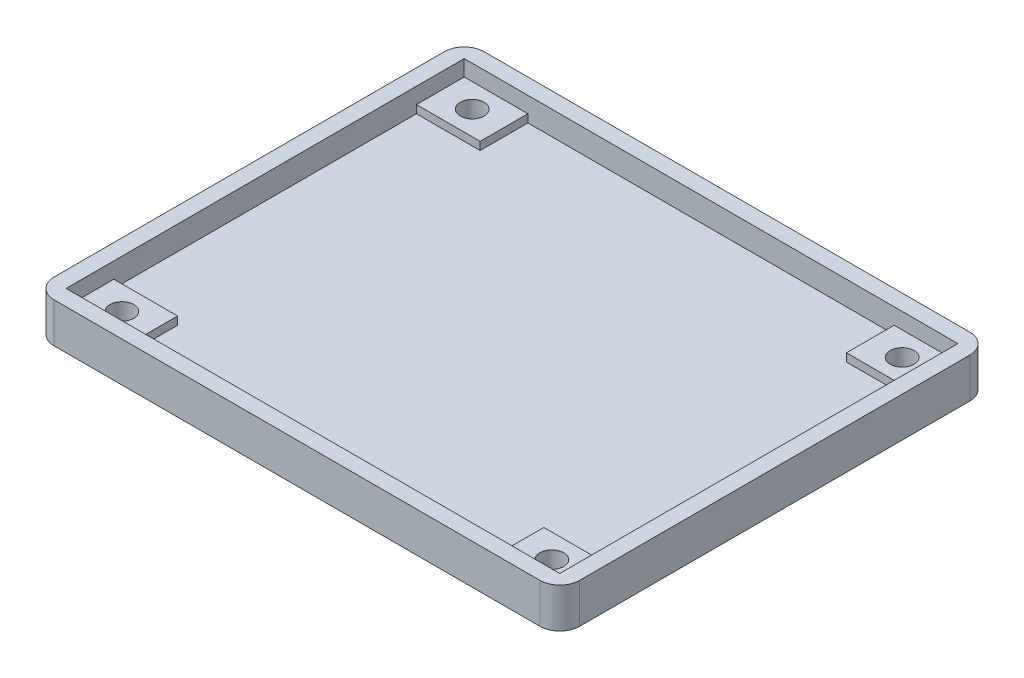
from build123d import *

# Parameters (mm, degrees)
SKETCH1_W           = 66
SKETCH1_H           = 54
BOSS_EXTRUDE1_DEPTH = 5
SKETCH2_W           = 62
SKETCH2_H           = 50
CUT_EXTRUDE1_DEPTH  = 3
SKETCH3_W           = 8
SKETCH3_H           = 6
SKETCH3_R           = 1.5
BOSS_EXTRUDE2_DEPTH = 3
SKETCH4_R           = 1.5
CUT_EXTRUDE2_DEPTH  = 3
FILLET1_R           = 2.5


with BuildPart() as part:
    # Sketch1 → Boss-Extrude1 (new body)
    with BuildSketch(Plane(origin=(0, 0, 0), x_dir=(1, 0, 0), z_dir=(0, 1, 0))):
        Rectangle(SKETCH1_W, SKETCH1_H)
    extrude(amount=BOSS_EXTRUDE1_DEPTH)

    # Sketch2 → Cut-Extrude1 (cut)
    with BuildSketch(Plane(origin=(0, 5, 0), x_dir=(1, 0, 0), z_dir=(0, 1, 0))):
        Rectangle(SKETCH2_W, SKETCH2_H)
    extrude(amount=-CUT_EXTRUDE1_DEPTH, mode=Mode.SUBTRACT)

    # Sketch3 → Boss-Extrude2 (add)
    with BuildSketch(Plane(origin=(0, 0, 0), x_dir=(1, 0, 0), z_dir=(0, 1, 0))):
        with Locations((-27, -22)):
            Rectangle(SKETCH3_W, SKETCH3_H)
        with Locations((-27, -22)):
            Circle(SKETCH3_R, mode=Mode.SUBTRACT)
        with Locations((-27, 22)):
            Rectangle(SKETCH3_W, SKETCH3_H)
        with Locations((-27, 22)):
            Circle(SKETCH3_R, mode=Mode.SUBTRACT)
        with Locations((27, -22)):
            Rectangle(SKETCH3_W, SKETCH3_H)
        with Locations((27, -22)):
            Circle(SKETCH3_R, mode=Mode.SUBTRACT)
        with Locations((27, 22)):
            Rectangle(SKETCH3_W, SKETCH3_H)
        with Locations((27, 22)):
            Circle(SKETCH3_R, mode=Mode.SUBTRACT)
    extrude(amount=BOSS_EXTRUDE2_DEPTH)

    # Sketch4 → Cut-Extrude2 (cut)
    with BuildSketch(Plane(origin=(0, 2, 0), x_dir=(1, 0, 0), z_dir=(0, 1, 0))):
        with Locations((-27, 22)):
            Circle(SKETCH4_R)
        with Locations((-27, -22)):
            Circle(SKETCH4_R)
        with Locations((27, -22)):
            Circle(SKETCH4_R)
        with Locations((27, 22)):
            Circle(SKETCH4_R)
    extrude(amount=-CUT_EXTRUDE2_DEPTH, mode=Mode.SUBTRACT)

    # Fillet1
    fillet1_edges = [part.edges().sort_by_distance(p)[0] for p in [
        (33, 2.5, 27),
        (-33, 2.5, 27),
        (-33, 2.5, -27),
        (33, 2.5, -27),
    ]]
    fillet(fillet1_edges, radius=FILLET1_R)


solid = part.part
